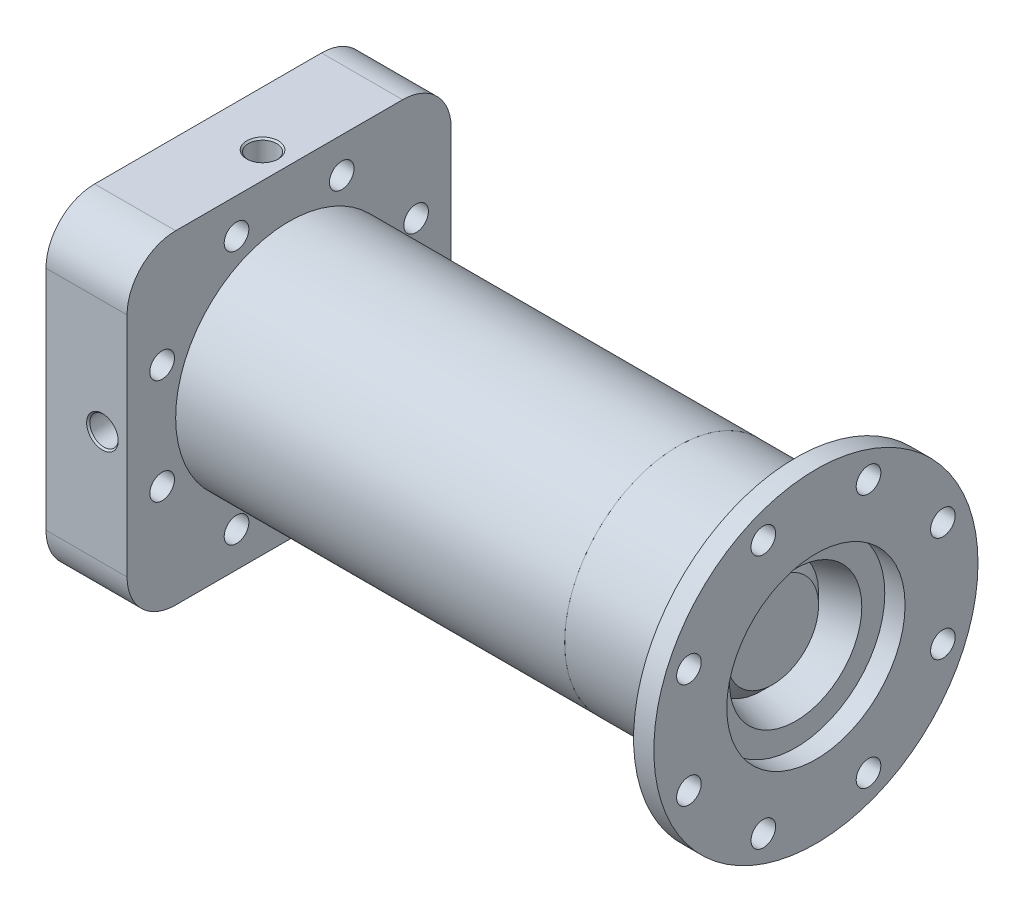
from build123d import *

# Parameters (mm, degrees)
FILLET1_R               = 1.27
CUT_EXTRUDE1_REACH      = 243.296
SKETCH2_R               = 3.81
CIRPATTERN1_COUNT       = 8
SKETCH4_R               = 63.5
BOSS_EXTRUDE1_DEPTH     = 31.75
SKETCH11_W              = 127
SKETCH11_H              = 127
SKETCH11_R              = 63.5
BOSS_EXTRUDE2_DEPTH     = 31.75
SKETCH12_R              = 24.13
CUT_EXTRUDE4_DEPTH      = 16.51
CUT_EXTRUDE5_START      = -39.450428
SKETCH13_R              = 1.9685
CUT_EXTRUDE5_DEPTH      = 39.450428
CHAMFER1_SIZE           = 4.572
FILLET2_R               = 0.889
FILLET3_R               = 0.508
CUT_EXTRUDE9_REACH      = 267.18
CUT_EXTRUDE9_END_RADIUS = 24.13
SKETCH31_R              = 1.5875
SKETCH33_R              = 44.45
SKETCH33_R_2            = 34.925
BOSS_EXTRUDE4_DEPTH     = 152.4
FILLET5_R               = 1.27
FILLET6_R               = 19.05
SKETCH39_R              = 63.5
SKETCH39_R_2            = 34.925
BOSS_EXTRUDE6_DEPTH     = 7.9375
SKETCH40_R              = 4.826
CUT_EXTRUDE13_DEPTH     = 248.100209245
CIRPATTERN3_COUNT       = 8
SKETCH44_R              = 1.7653


with BuildPart() as part:
    # Chamber Revolve → Revolve1 (revolve)
    with BuildSketch(Plane.XY, mode=Mode.PRIVATE) as revolve1_sk:
        with BuildLine():
            Line((223.962313951, 63.5), (223.962313951, 25.908))
            Line((223.962313951, 25.908), (191.916500941, 17.321350283))
            ThreePointArc((191.916500941, 17.321350283), (190.601700192, 17.321350283), (189.463049342, 17.978750658))
            Line((189.463049342, 17.978750658), (173.5582, 33.8836))
            Line((173.5582, 33.8836), (0, 33.8836))
            Line((0, 33.8836), (0, 42.5196))
            Line((0, 42.5196), (3.8608, 42.5196))
            Line((3.8608, 42.5196), (3.8608, 48.5902))
            Line((3.8608, 48.5902), (0, 48.5902))
            Line((0, 48.5902), (0, 63.5))
            Line((0, 63.5), (10.16, 63.5))
            Line((10.16, 63.5), (10.16, 47.5996))
            Line((10.16, 47.5996), (24.13, 47.5996))
            Line((24.13, 47.5996), (24.13, 63.5))
            Line((24.13, 63.5), (223.962313951, 63.5))
        make_face()
    revolve(revolve1_sk.sketch.rotate(Axis((0, 0, 0), (1, 0, 0)), 90), axis=Axis((0, 0, 0), (1, 0, 0)))

    # Fillet1
    fillet1_edges = [part.edges().sort_by_distance(p)[0] for p in [
        (24.13, 0, -47.5996),
        (10.16, 0, -47.5996),
    ]]
    fillet(fillet1_edges, radius=FILLET1_R)

    # Sketch2 → Cut-Extrude1 (cut, up to next)
    with BuildSketch(Plane.ZY, mode=Mode.PRIVATE) as cut_extrude1_sk1:
        with Locations((-21.773156568, 52.565049882)):
            Circle(SKETCH2_R)
    cut_extrude1_tool1 = extrude(cut_extrude1_sk1.sketch, amount=-CUT_EXTRUDE1_REACH, mode=Mode.PRIVATE) & part.part
    cut_extrude1 = cut_extrude1_tool1.solids().sort_by_distance((0, 52.56505, -21.773157))[0]
    add(cut_extrude1, mode=Mode.SUBTRACT)

    # CirPattern1: Cut-Extrude1 ×8 about axis
    cirpattern1_axis = Axis((0, 0, 0), (1, 0, 0))
    for i in range(1, CIRPATTERN1_COUNT):
        add(cut_extrude1.rotate(cirpattern1_axis, i * 360 / CIRPATTERN1_COUNT), mode=Mode.SUBTRACT)

    # Fillet2
    fillet2_edges = [part.edges().sort_by_distance(p)[0] for p in [
        (3.8608, 0, -42.5196),
        (3.8608, 0, -48.5902),
    ]]
    fillet(fillet2_edges, radius=FILLET2_R)


with BuildPart() as body_2:
    # Sketch4 → Boss-Extrude1 (new body)
    with BuildSketch(Plane.ZY):
        Circle(SKETCH4_R)
    extrude(amount=BOSS_EXTRUDE1_DEPTH)


with BuildPart() as boss_extrude2_tool:
    # Sketch11 → Boss-Extrude2 (new body)
    with BuildSketch(Plane.ZY.offset(31.75)):
        Rectangle(SKETCH11_W, SKETCH11_H)
        Circle(SKETCH11_R, mode=Mode.SUBTRACT)
    extrude(amount=-BOSS_EXTRUDE2_DEPTH)


with BuildPart() as body_2_1:
    add(body_2.part)


with BuildPart() as body_2_2:
    # Boss-Extrude2: joined with boss_extrude2_tool
    add(body_2_1.part.fuse(boss_extrude2_tool.part, tol=0.00001))


with BuildPart() as boss_extrude2_kept_piece:
    # of the separate pieces the step leaves, the one the design keeps (boss_extrude2_pieces_kept)
    add(body_2_2.part.solids().sort_by_distance((-31.75, -63.5, 63.5))[0])

    # Sketch12 → Cut-Extrude4 (cut)
    with BuildSketch(Plane(origin=(0, 0, 0), x_dir=(0, 0, -1), z_dir=(1, 0, 0))):
        Circle(SKETCH12_R)
    extrude(amount=-CUT_EXTRUDE4_DEPTH, mode=Mode.SUBTRACT)

    # Sketch13 → Cut-Extrude5 (cut)
    with BuildSketch(Plane.XY.offset(63.5).offset(CUT_EXTRUDE5_START)):
        with Locations((-9.652, 0)):
            Circle(SKETCH13_R)
    cut_extrude5 = extrude(amount=CUT_EXTRUDE5_DEPTH, mode=Mode.SUBTRACT)

    # Chamfer1
    chamfer1_edges = [boss_extrude2_kept_piece.edges().sort_by_distance(p)[0] for p in [
        (0, 0, 24.13),
    ]]
    chamfer(chamfer1_edges, length=CHAMFER1_SIZE)

    # Sketch20 → 7/16 (0.4375) Diameter Hole1 (revolve, cut)
    with BuildSketch(Plane(origin=(-9.652, 0, 63.5), x_dir=(0, -1, 0), z_dir=(1, 0, 0))):
        Polygon((0, 0), (0, 22.388531814), (5.55625, 19.05), (5.55625, 0.635), (6.19125, 0), align=None)
    f_7_16_0_4375_diameter_hole1 = revolve(axis=Axis((-9.652, 0, 69.85), (0, 0, -1)), mode=Mode.SUBTRACT)

    # Mirror1: Cut-Extrude5, 7/16 (0.4375) Diameter Hole1 across plane
    add(cut_extrude5.mirror(Plane.XY), mode=Mode.SUBTRACT)
    add(f_7_16_0_4375_diameter_hole1.mirror(Plane.XY), mode=Mode.SUBTRACT)

    # Sketch23 → Ø6.7 (6.7) Diameter Hole1 (revolve, cut)
    with BuildSketch(Plane(origin=(-31.75, -33.02, 0), x_dir=(0, 0, 1), z_dir=(0, 1, 0))):
        Polygon((0, 0), (0, 15.220883074), (3.35, 13.208), (3.35, 0.4), (3.75, 0), align=None)
    f_6_7_6_7_diameter_hole1 = revolve(axis=Axis((-38.1, -33.02, 0), (1, 0, 0)), mode=Mode.SUBTRACT)

    # Mirror2: Ø6.7 (6.7) Diameter Hole1 across plane
    add(f_6_7_6_7_diameter_hole1.mirror(Plane.ZX), mode=Mode.SUBTRACT)

    # Sketch24 → Cut-Revolve1 (revolve, cut)
    with BuildSketch(Plane(origin=(0, 0, 0), x_dir=(1, 0, 0), z_dir=(0, 1, 0))):
        with BuildLine():
            Line((-31.75, 7.1374), (-30.958106371, 5.7658))
            Line((-30.958106371, 5.7658), (-29.845, 5.7658))
            ThreePointArc((-29.845, 5.7658), (-29.650596816, 5.727130803), (-29.485789755, 5.617010245))
            Line((-29.485789755, 5.617010245), (-28.73287951, 4.8641))
            Line((-28.73287951, 4.8641), (-16.51, 4.8641))
            Line((-16.51, 4.8641), (-16.51, 0))
            Line((-16.51, 0), (-31.75, 0))
            Line((-31.75, 0), (-31.75, 7.1374))
        make_face()
    revolve(axis=Axis((223.962313951, 0, 0), (-1, 0, 0)), mode=Mode.SUBTRACT)

    # Fillet3
    fillet3_edges = [boss_extrude2_kept_piece.edges().sort_by_distance(p)[0] for p in [
        (-30.958106371, 0, 5.7658),
    ]]
    fillet(fillet3_edges, radius=FILLET3_R)

    # Sketch30 → 7/16 (0.4375) Diameter Hole2 (revolve, cut)
    with BuildSketch(Plane(origin=(-10.414, -63.5, 0), x_dir=(0, 0, -1), z_dir=(1, 0, 0))):
        Polygon((0, 0), (0, 22.388531814), (5.55625, 19.05), (5.55625, 0.635), (6.19125, 0), align=None)
    f_7_16_0_4375_diameter_hole2 = revolve(axis=Axis((-10.414, -69.85, 0), (0, 1, 0)), mode=Mode.SUBTRACT)

    # Cut-Extrude9: up to this cylinder (the profile starts outside it)
    cut_extrude9_end = Plane(origin=(-10.414, 0, 0), z_dir=(1, 0, 0)) * Cylinder(CUT_EXTRUDE9_END_RADIUS, 583.62, mode=Mode.PRIVATE)
    # Sketch31 → Cut-Extrude9 (cut, up to the surface)
    with BuildSketch(Plane.XZ.offset(63.5), mode=Mode.PRIVATE) as cut_extrude9_sk1:
        with Locations(Location((-10.414, 0, 0), (0, 0, 270))):
            Circle(SKETCH31_R)
    cut_extrude9_tool1 = extrude(cut_extrude9_sk1.sketch, amount=-CUT_EXTRUDE9_REACH, mode=Mode.PRIVATE) - cut_extrude9_end
    cut_extrude9 = cut_extrude9_tool1.solids().sort_by_distance((-10.414, -63.5, 0))[0]
    add(cut_extrude9, mode=Mode.SUBTRACT)

    # Mirror3: 7/16 (0.4375) Diameter Hole2, Cut-Extrude9 across plane
    add(f_7_16_0_4375_diameter_hole2.mirror(Plane.ZX), mode=Mode.SUBTRACT)
    add(cut_extrude9.mirror(Plane.ZX), mode=Mode.SUBTRACT)

    # Fillet6
    fillet6_edges = [boss_extrude2_kept_piece.edges().sort_by_distance(p)[0] for p in [
        (-15.875, -63.5, 63.5),
        (-15.875, 63.5, 63.5),
        (-15.875, -63.5, -63.5),
        (-15.875, 63.5, -63.5),
    ]]
    fillet(fillet6_edges, radius=FILLET6_R)


with BuildPart() as body_3:
    # Sketch21 → Revolve2 (revolve)
    with BuildSketch(Plane(origin=(0, 0, 0), x_dir=(1, 0, 0), z_dir=(0, 1, 0))):
        Polygon((0, 33.8836), (173.5582, 33.8836), (189.463049342, 17.978750658), (189.463049342, 0), (0, 0), align=None)
    revolve(axis=Axis((189.463049342, 0, 0), (1, 0, 0)))


with BuildPart() as body_3_2:
    # Sketch33 → Boss-Extrude4 (new body)
    with BuildSketch(Plane(origin=(0, 0, 0), x_dir=(0, 0, -1), z_dir=(1, 0, 0))):
        with Locations(Location((0, 0, 0), (0, 0, 180))):
            Circle(SKETCH33_R)
        with Locations(Location((0, 0, 0), (0, 0, 180))):
            Circle(SKETCH33_R_2, mode=Mode.SUBTRACT)
    extrude(amount=BOSS_EXTRUDE4_DEPTH)


with BuildPart() as body_4:
    # Sketch34 → Revolve3 (revolve)
    with BuildSketch(Plane.XY, mode=Mode.PRIVATE) as revolve3_sk:
        Polygon((152.4, 44.45), (152.4, 34.925), (164.991972201, 16.9418), (198.454286152, 25.908), (198.454286152, 44.45), align=None)
    revolve(revolve3_sk.sketch.rotate(Axis((152.4, 0, 0), (-1, 0, 0)), 90), axis=Axis((152.4, 0, 0), (-1, 0, 0)))

    # Fillet5
    fillet5_edges = [body_4.edges().sort_by_distance(p)[0] for p in [
        (164.991972201, 0, 16.9418),
    ]]
    fillet(fillet5_edges, radius=FILLET5_R)

    # Sketch45 → Cut-Revolve3 (revolve, cut)
    with BuildSketch(Plane.XY, mode=Mode.PRIVATE) as cut_revolve3_sk:
        with BuildLine():
            Line((152.4, 41.4274), (154.5336, 41.4274))
            ThreePointArc((154.5336, 41.4274), (154.892810245, 41.278610245), (155.0416, 40.9194))
            Line((155.0416, 40.9194), (155.0416, 37.846))
            ThreePointArc((155.0416, 37.846), (154.892810245, 37.486789755), (154.5336, 37.338))
            Line((154.5336, 37.338), (152.4, 37.338))
            Line((152.4, 37.338), (152.4, 41.4274))
        make_face()
    revolve(cut_revolve3_sk.sketch.rotate(Axis((0, 0, 0), (1, 0, 0)), 90), axis=Axis((0, 0, 0), (1, 0, 0)), mode=Mode.SUBTRACT)


with BuildPart() as body_5:
    # Sketch39 → Boss-Extrude6 (new body)
    with BuildSketch(Plane(origin=(198.454286152, 0, 0), x_dir=(0, 0, -1), z_dir=(1, 0, 0))):
        Circle(SKETCH39_R)
        Circle(SKETCH39_R_2, mode=Mode.SUBTRACT)
    extrude(amount=BOSS_EXTRUDE6_DEPTH)


with BuildPart() as cut_extrude13_tool:
    # Sketch40 → Cut-Extrude13 (new, symmetric)
    with BuildSketch(Plane.ZY.offset(-198.454286152)):
        with Locations(Location((-20.606737466, 49.749065067, 0), (0, 0, 180))):
            Circle(SKETCH40_R)
    cut_extrude13 = extrude(amount=CUT_EXTRUDE13_DEPTH, both=True)


with BuildPart() as boss_extrude2_kept_piece_1:
    add(boss_extrude2_kept_piece.part)

    # Cut-Extrude13: cut by cut_extrude13_tool
    add(cut_extrude13_tool.part, mode=Mode.SUBTRACT)


with BuildPart() as body_5_1:
    add(body_5.part)

    # Cut-Extrude13: cut by cut_extrude13_tool
    add(cut_extrude13_tool.part, mode=Mode.SUBTRACT)


with BuildPart() as cirpattern3_tool:
    # CirPattern3: Cut-Extrude13 ×8 about axis
    cirpattern3_axis = Axis((0, 0, 0), (1, 0, 0))
    for i in range(1, CIRPATTERN3_COUNT):
        add(cut_extrude13.rotate(cirpattern3_axis, i * 360 / CIRPATTERN3_COUNT))


with BuildPart() as boss_extrude2_kept_piece_2:
    add(boss_extrude2_kept_piece_1.part)

    # CirPattern3: cut by cirpattern3_tool
    add(cirpattern3_tool.part, mode=Mode.SUBTRACT)

    # Sketch41 → Cut-Revolve2 (revolve, cut)
    with BuildSketch(Plane.XY, mode=Mode.PRIVATE) as cut_revolve2_sk:
        with BuildLine():
            Line((0, 37.338), (-2.1844, 37.338))
            ThreePointArc((-2.1844, 37.338), (-2.50768922, 37.47191078), (-2.6416, 37.7952))
            Line((-2.6416, 37.7952), (-2.6416, 40.9702))
            ThreePointArc((-2.6416, 40.9702), (-2.50768922, 41.29348922), (-2.1844, 41.4274))
            Line((-2.1844, 41.4274), (0, 41.4274))
            Line((0, 41.4274), (0, 37.338))
        make_face()
    revolve(cut_revolve2_sk.sketch.rotate(Axis((0, 0, 0), (1, 0, 0)), 90), axis=Axis((0, 0, 0), (1, 0, 0)), mode=Mode.SUBTRACT)


with BuildPart() as body_5_2:
    add(body_5_1.part)

    # CirPattern3: cut by cirpattern3_tool
    add(cirpattern3_tool.part, mode=Mode.SUBTRACT)


with BuildPart() as body_6:
    # Sketch44 → Revolve4 (revolve)
    with BuildSketch(Plane.XY, mode=Mode.PRIVATE) as revolve4_sk:
        with Locations((-0.8763, 39.6621)):
            Circle(SKETCH44_R)
    revolve(revolve4_sk.sketch.rotate(Axis((0, 0, 0), (1, 0, 0)), 90), axis=Axis((0, 0, 0), (1, 0, 0)))


with BuildPart() as body_7:
    # Mirror9: mirrored copy
    add(body_6.part.mirror(Plane(origin=(76.2, 0, 0), x_dir=(0, 0, 1), z_dir=(1, 0, 0))))


solid = Compound([body_3.part, body_3_2.part, body_4.part, boss_extrude2_kept_piece_2.part, body_5_2.part, body_6.part, body_7.part])
